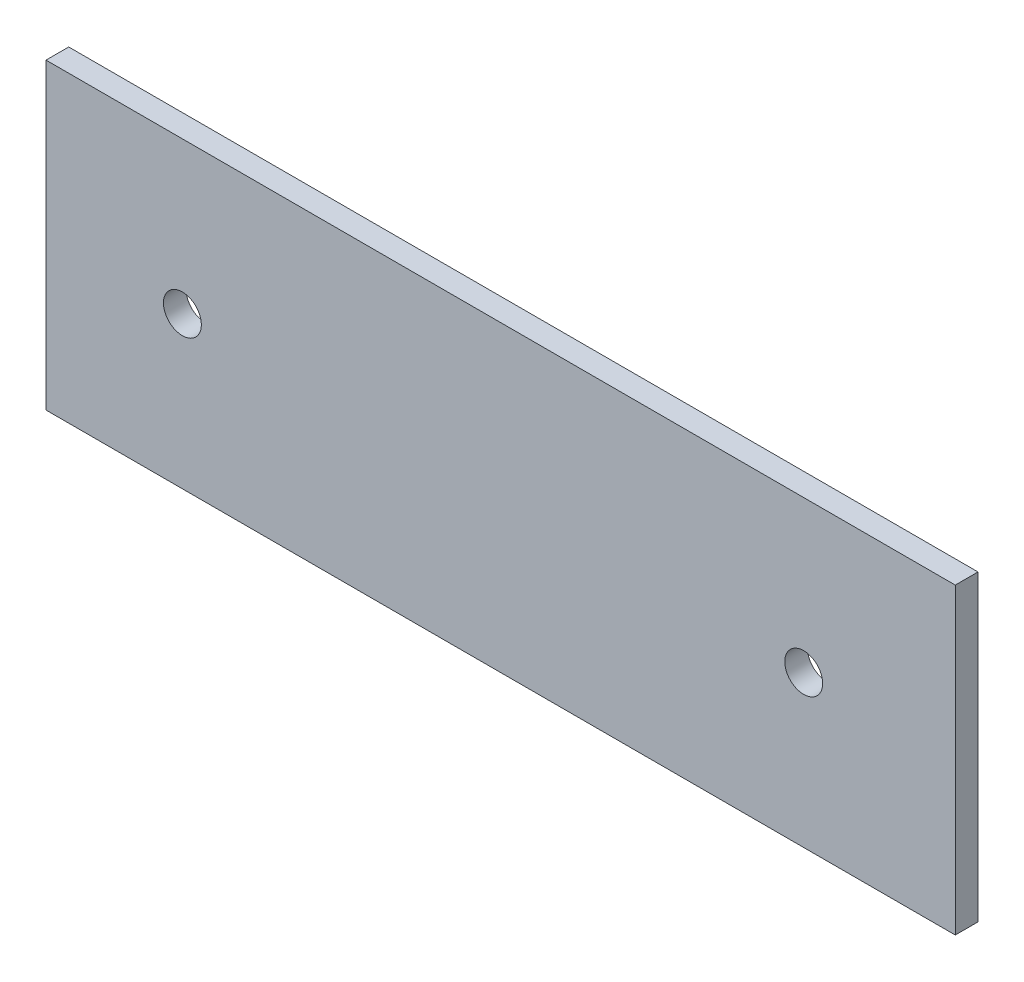
from build123d import *

# Parameters (mm, degrees)
SCHIZZO1_W                   = 120
SCHIZZO1_H                   = 40
ESTRUSIONE_ESTRUSIONE1_DEPTH = 3
SCHIZZO2_R                   = 2.5
TAGLIO_ESTRUSIONE1_DEPTH     = 3
SCHIZZO3_R                   = 2.5
TAGLIO_ESTRUSIONE2_DEPTH     = 3


with BuildPart() as part:
    # Schizzo1 → Estrusione-Estrusione1 (new body)
    with BuildSketch(Plane.XY):
        with Locations((60, -20)):
            Rectangle(SCHIZZO1_W, SCHIZZO1_H)
    extrude(amount=ESTRUSIONE_ESTRUSIONE1_DEPTH)

    # Schizzo2 → Taglio-Estrusione1 (cut)
    with BuildSketch(Plane.XY.offset(3)):
        with Locations((18, -20)):
            Circle(SCHIZZO2_R)
    extrude(amount=-TAGLIO_ESTRUSIONE1_DEPTH, mode=Mode.SUBTRACT)

    # Schizzo3 → Taglio-Estrusione2 (cut)
    with BuildSketch(Plane.XY.offset(3)):
        with Locations((100, -20)):
            Circle(SCHIZZO3_R)
    extrude(amount=-TAGLIO_ESTRUSIONE2_DEPTH, mode=Mode.SUBTRACT)


solid = part.part
